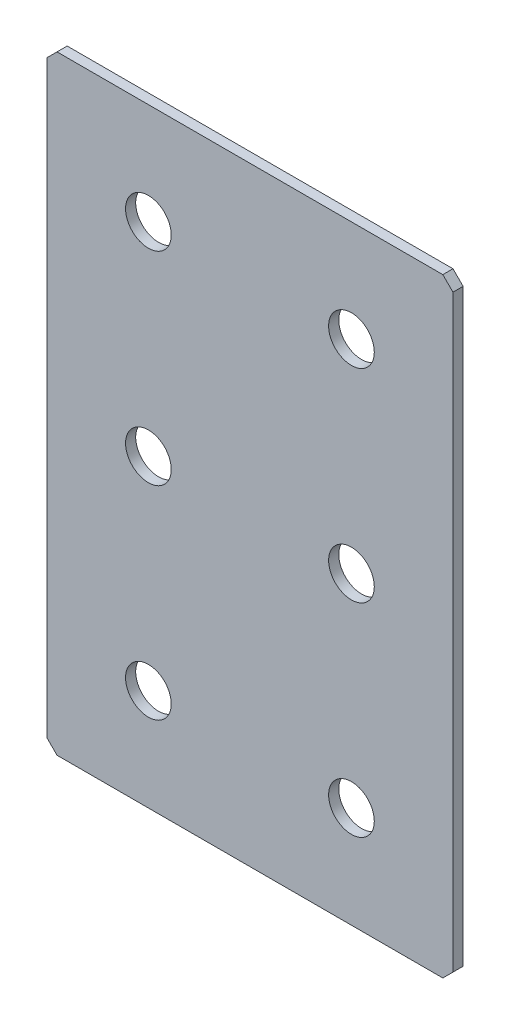
from build123d import *

# Parameters (mm, degrees)
SKETCH_1_W        = 80
SKETCH_1_H        = 120
EXTRUDE_1_DEPTH   = 2
CHAMFER_1_SIZE    = 2
HOLE_WIZARD_M81_D = 9


with BuildPart() as part:
    # Эскиз1 → Бобышка-Вытянуть1 (new body)
    with BuildSketch(Plane.XY):
        Rectangle(SKETCH_1_W, SKETCH_1_H)
    extrude(amount=EXTRUDE_1_DEPTH)

    # Фаска1
    chamfer_1_edges = [part.edges().sort_by_distance(p)[0] for p in [
        (40, -60, 1),
        (-40, -60, 1),
        (-40, 60, 1),
        (40, 60, 1),
    ]]
    chamfer(chamfer_1_edges, length=CHAMFER_1_SIZE)

    # Отверстие с зазором M81 (through all)
    with Locations(Plane.XY.offset(2)):
        with Locations((-20, 40), (20, 40), (20, 0), (-20, 0), (-20, -40), (20, -40)):
            Hole(HOLE_WIZARD_M81_D / 2)


solid = part.part
